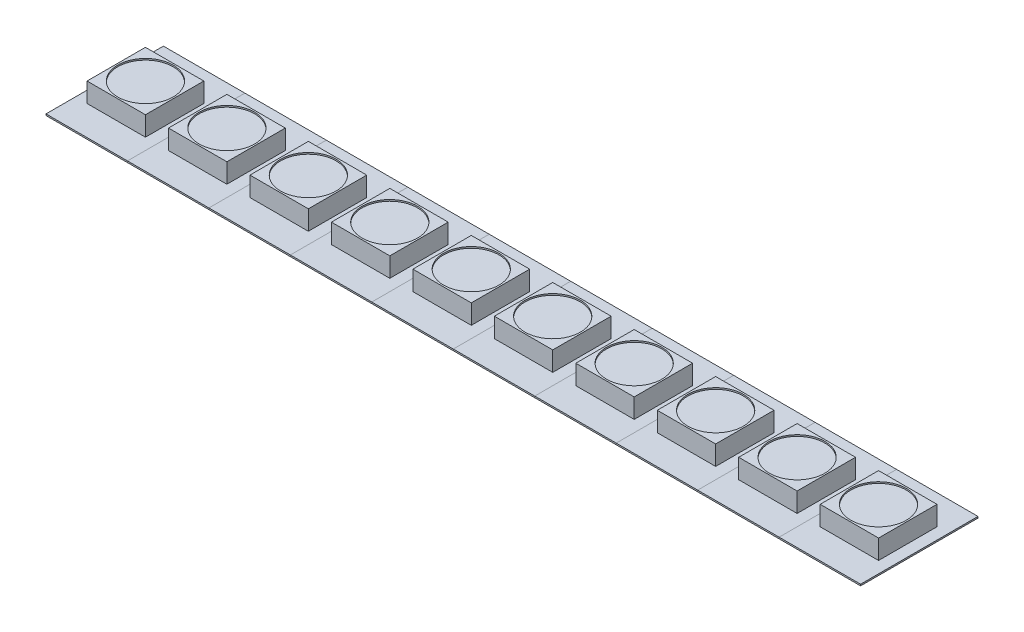
from build123d import *

# Parameters (mm, degrees)
SKETCH1_W           = 6.9088
SKETCH1_H           = 9.9568
BOSS_EXTRUDE1_DEPTH = 0.127
SKETCH3_W           = 4.953
SKETCH3_H           = 4.953
BOSS_EXTRUDE3_DEPTH = 1.651
SKETCH5_R           = 2.348345572
CUT_EXTRUDE1_DEPTH  = 0.127
LPATTERN1_COUNT     = 10
LPATTERN1_PITCH     = 6.9088


with BuildPart() as part:
    # Sketch1 → Boss-Extrude1 (new body)
    with BuildSketch(Plane(origin=(0, 0, 0), x_dir=(1, 0, 0), z_dir=(0, 1, 0))):
        Rectangle(SKETCH1_W, SKETCH1_H)
    extrude(amount=BOSS_EXTRUDE1_DEPTH)

    # Sketch3 → Boss-Extrude3 (add)
    with BuildSketch(Plane(origin=(0, 0.127, 0), x_dir=(1, 0, 0), z_dir=(0, 1, 0))):
        Rectangle(SKETCH3_W, SKETCH3_H)
    extrude(amount=BOSS_EXTRUDE3_DEPTH)

    # Sketch5 → Cut-Extrude1 (cut)
    with BuildSketch(Plane(origin=(0, 1.778, 0), x_dir=(1, 0, 0), z_dir=(0, 1, 0))):
        Circle(SKETCH5_R)
    extrude(amount=-CUT_EXTRUDE1_DEPTH, mode=Mode.SUBTRACT)


with BuildPart() as lpattern1_1:
    # LPattern1: pattern copy
    add(part.part.moved(Location(Vector(1, 0, 0) * (1 * LPATTERN1_PITCH))))


with BuildPart() as lpattern1_2:
    # LPattern1: pattern copy
    add(part.part.moved(Location(Vector(1, 0, 0) * (2 * LPATTERN1_PITCH))))


with BuildPart() as lpattern1_3:
    # LPattern1: pattern copy
    add(part.part.moved(Location(Vector(1, 0, 0) * (3 * LPATTERN1_PITCH))))


with BuildPart() as lpattern1_4:
    # LPattern1: pattern copy
    add(part.part.moved(Location(Vector(1, 0, 0) * (4 * LPATTERN1_PITCH))))


with BuildPart() as lpattern1_5:
    # LPattern1: pattern copy
    add(part.part.moved(Location(Vector(1, 0, 0) * (5 * LPATTERN1_PITCH))))


with BuildPart() as lpattern1_6:
    # LPattern1: pattern copy
    add(part.part.moved(Location(Vector(1, 0, 0) * (6 * LPATTERN1_PITCH))))


with BuildPart() as lpattern1_7:
    # LPattern1: pattern copy
    add(part.part.moved(Location(Vector(1, 0, 0) * (7 * LPATTERN1_PITCH))))


with BuildPart() as lpattern1_8:
    # LPattern1: pattern copy
    add(part.part.moved(Location(Vector(1, 0, 0) * (8 * LPATTERN1_PITCH))))


with BuildPart() as lpattern1_9:
    # LPattern1: pattern copy
    add(part.part.moved(Location(Vector(1, 0, 0) * (9 * LPATTERN1_PITCH))))


solid = Compound([part.part, lpattern1_1.part, lpattern1_2.part, lpattern1_3.part, lpattern1_4.part, lpattern1_5.part, lpattern1_6.part, lpattern1_7.part, lpattern1_8.part, lpattern1_9.part])
